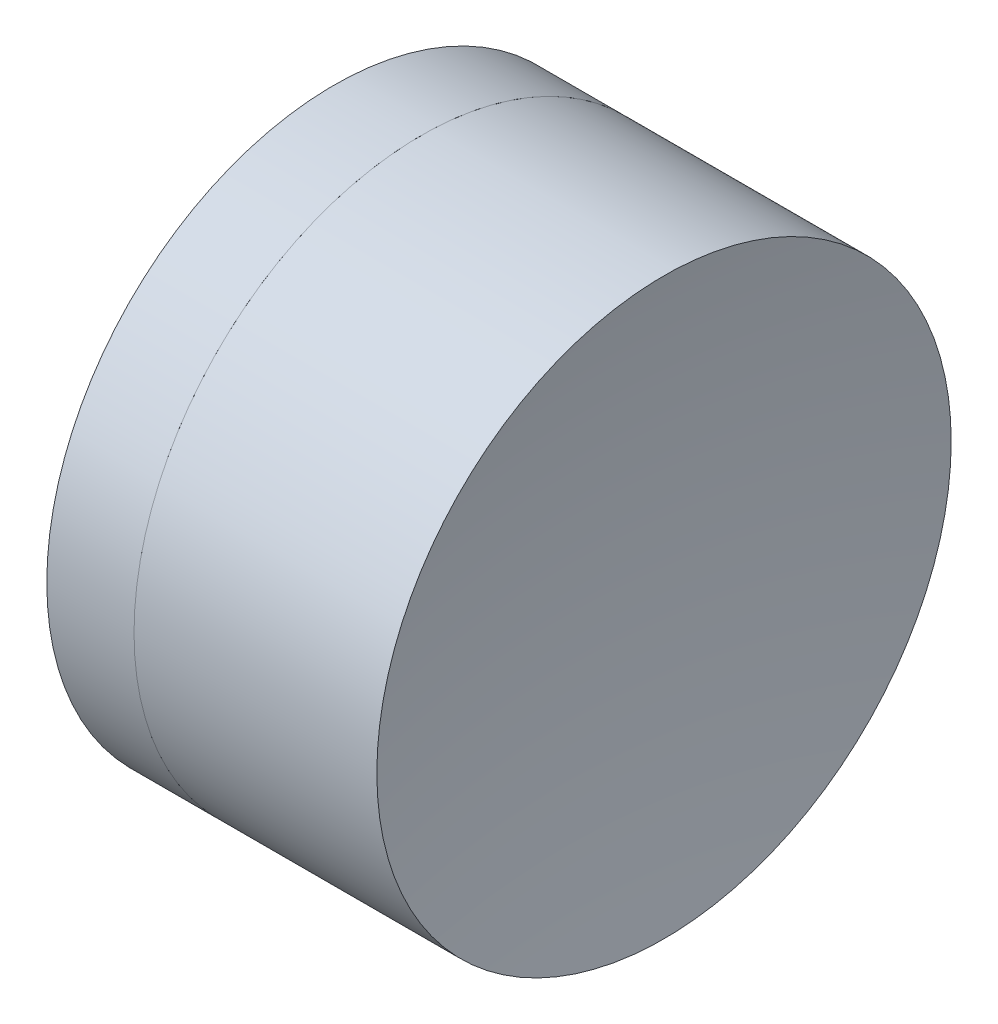
from build123d import *


with BuildPart() as part:
    # 草图1 one side → 旋转1 (revolve)
    with BuildSketch(Plane(origin=(0, 0, 0), x_dir=(1, 0, 0), z_dir=(0, 1, 0)), mode=Mode.PRIVATE) as revolve_1_sk:
        with BuildLine():
            ThreePointArc((2.569476157, 2.5), (2.09684926, 1.289502186), (1.936022485, 0))
            Line((1.936022485, 0), (3.936022485, 0))
            ThreePointArc((3.936022485, 0), (3.782041782, 1.2863435), (3.328800613, 2.5))
            Line((3.328800613, 2.5), (2.569476157, 2.5))
        make_face()
    revolve(revolve_1_sk.sketch.rotate(Axis((-0.816062176, 0, 0), (1, 0, 0)), 180), axis=Axis((-0.816062176, 0, 0), (1, 0, 0)))  # turned: the seam where the file's is


with BuildPart() as body_2:
    # 草图2 one side → 旋转2 (revolve)
    with BuildSketch(Plane(origin=(0, 0, 0), x_dir=(1, 0, 0), z_dir=(0, 1, 0)), mode=Mode.PRIVATE) as revolve_2_sk:
        with BuildLine():
            Line((5.442473336, 2.5), (3.328800613, 2.5))
            ThreePointArc((3.328800613, 2.5), (3.782041782, 1.2863435), (3.936022485, 0))
            Line((3.936022485, 0), (5.236022485, 0))
            ThreePointArc((5.236022485, 0), (5.287722892, 1.254254954), (5.442473336, 2.5))
        make_face()
    revolve(revolve_2_sk.sketch.rotate(Axis((-0.551919993, 0, 0), (1, 0, 0)), 180), axis=Axis((-0.551919993, 0, 0), (1, 0, 0)))  # turned: the seam where the file's is


solid = Compound([part.part, body_2.part])
